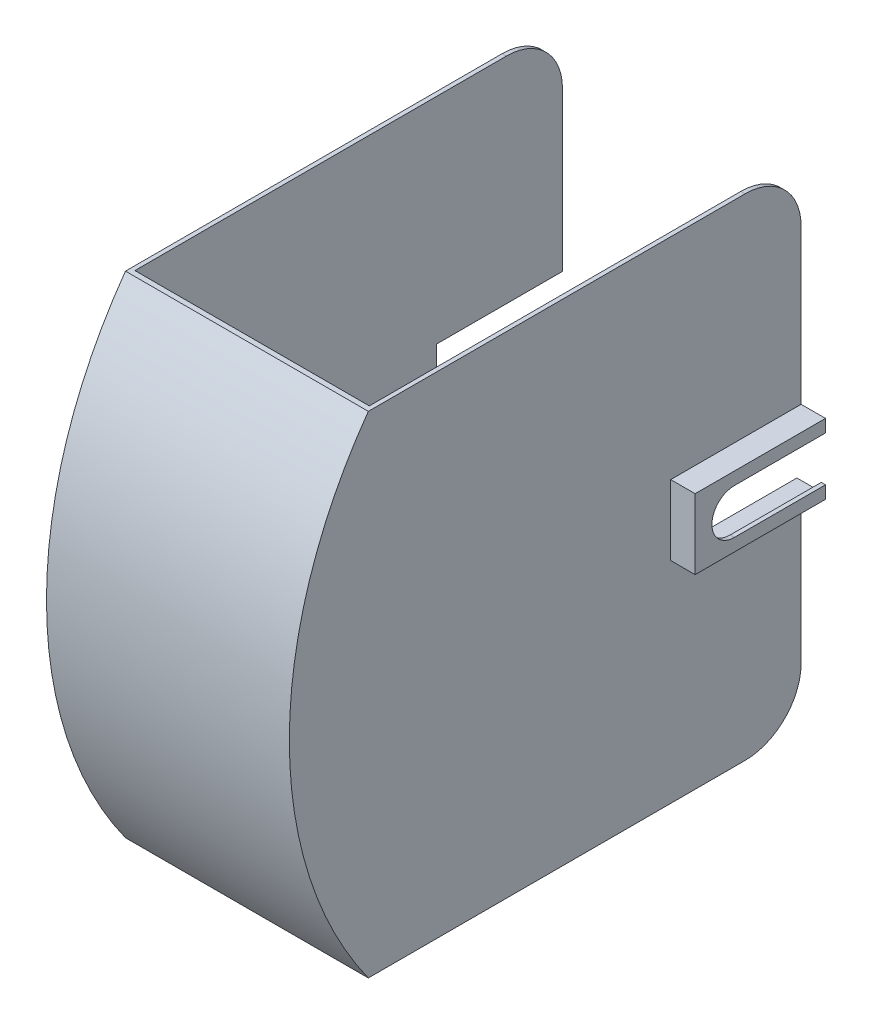
from build123d import *

# Parameters (mm, degrees)
BOSS_EXTRUDE1_DEPTH  = 90
CUT_EXTRUDE1_DEPTH   = 15
SKETCH4_W            = 3
SKETCH4_H            = 90
BOSS_EXTRUDE3_DEPTH  = 150
SKETCH5_W            = 3
SKETCH5_H            = 90
BOSS_EXTRUDE4_DEPTH  = 150
SKETCH12_W           = 20.399999779
SKETCH12_H           = 3
BOSS_EXTRUDE5_DEPTH  = 3
SKETCH13_W           = 20.399999779
SKETCH13_H           = 3
BOSS_EXTRUDE6_DEPTH  = 47
SKETCH15_W           = 3
SKETCH15_H           = 150
BOSS_EXTRUDE7_DEPTH  = 3
SKETCH16_W           = 3
SKETCH16_H           = 150
BOSS_EXTRUDE8_DEPTH  = 3
SKETCH17_W           = 3
SKETCH17_H           = 350
BOSS_EXTRUDE9_DEPTH  = 293
CUT_EXTRUDE2_DEPTH   = 263
BOSS_EXTRUDE10_DEPTH = 167.2
FILLET1_R            = 40


with BuildPart() as part:
    # Sketch2 → Boss-Extrude1 (new body)
    with BuildSketch(Plane.XY):
        Polygon((-54.932805324, 53.008197058), (-54.932805324, 97.008197058), (-72.332805103, 97.008197058), (-72.332805103, 100.008197058), (-51.932805324, 100.008197058), (-51.932805324, 50.008197058), (-72.332805103, 50.008197058), (-72.332805103, 53.008197058), align=None)
    extrude(amount=-BOSS_EXTRUDE1_DEPTH)

    # Sketch3 → Cut-Extrude1 (cut)
    with BuildSketch(Plane(origin=(-51.932805324, 0, 0), x_dir=(0, 0, -1), z_dir=(1, 0, 0))):
        with BuildLine():
            Line((25.000000095, 59.008197058), (90, 59.008197058))
            Line((90, 59.008197058), (90, 91.008197058))
            Line((90, 91.008197058), (25.000000095, 91.008197058))
            ThreePointArc((25.000000095, 91.008197058), (9.000000095, 75.008197058), (25.000000095, 59.008197058))
        make_face()
    extrude(amount=-CUT_EXTRUDE1_DEPTH, mode=Mode.SUBTRACT)

    # Sketch4 → Boss-Extrude3 (add)
    with BuildSketch(Plane.XZ.offset(-50.008197058)):
        with Locations((-70.832805103, -45)):
            Rectangle(SKETCH4_W, SKETCH4_H)
    extrude(amount=BOSS_EXTRUDE3_DEPTH)

    # Sketch5 → Boss-Extrude4 (add)
    with BuildSketch(Plane(origin=(0, 100.008197058, 0), x_dir=(1, 0, 0), z_dir=(0, 1, 0))):
        with Locations((-70.832805103, 45)):
            Rectangle(SKETCH5_W, SKETCH5_H)
    extrude(amount=BOSS_EXTRUDE4_DEPTH)

    # Sketch12 → Boss-Extrude5 (add)
    with BuildSketch(Plane.XY):
        with Locations((-62.132805213, 98.508197058)):
            Rectangle(SKETCH12_W, SKETCH12_H)
    extrude(amount=BOSS_EXTRUDE5_DEPTH)

    # Sketch13 → Boss-Extrude6 (add)
    with BuildSketch(Plane.XZ.offset(-97.008197058)):
        with Locations((-62.132805213, 1.5)):
            Rectangle(SKETCH13_W, SKETCH13_H)
    extrude(amount=BOSS_EXTRUDE6_DEPTH)

    # Sketch15 → Boss-Extrude7 (add)
    with BuildSketch(Plane.XY):
        with Locations((-70.832805103, -24.991802942)):
            Rectangle(SKETCH15_W, SKETCH15_H)
    extrude(amount=BOSS_EXTRUDE7_DEPTH)

    # Sketch16 → Boss-Extrude8 (add)
    with BuildSketch(Plane.XY):
        with Locations((-70.832805103, 175.008197058)):
            Rectangle(SKETCH16_W, SKETCH16_H)
    extrude(amount=BOSS_EXTRUDE8_DEPTH)

    # Sketch17 → Boss-Extrude9 (add)
    with BuildSketch(Plane.XY.offset(3)):
        with Locations((-70.832805103, 75.008197058)):
            Rectangle(SKETCH17_W, SKETCH17_H)
    extrude(amount=BOSS_EXTRUDE9_DEPTH)

    # Sketch18 → Cut-Extrude2 (cut)
    with BuildSketch(Plane(origin=(-69.332805103, 0, 0), x_dir=(0, 0, -1), z_dir=(1, 0, 0))):
        with BuildLine():
            Line((-218.669858525, -99.991802942), (-296, -99.991802942))
            Line((-296, -99.991802942), (-296, 250.008197058))
            Line((-296, 250.008197058), (-218.669858525, 250.008197058))
            ThreePointArc((-218.669858525, 250.008197058), (-274.999999905, 75.008197058), (-218.669858525, -99.991802942))
        make_face()
    extrude(amount=-CUT_EXTRUDE2_DEPTH, mode=Mode.SUBTRACT)


with BuildPart() as body_2:
    # Mirror3: mirrored copy
    add(part.part.mirror(Plane.ZY.offset(155.932805134)))


with BuildPart() as part_1:
    add(part.part)

    add(body_2.part)  # Boss-Extrude10 merges body 2
    # Sketch20 → Boss-Extrude10 (add)
    with BuildSketch(Plane.ZY.offset(72.332805103)):
        with BuildLine():
            Line((214.966664257, 250.008197058), (218.669858525, 250.008197058))
            ThreePointArc((218.669858525, 250.008197058), (274.999999905, 75.008197058), (218.669858525, -99.991802942))
            Line((218.669858525, -99.991802942), (214.966664257, -99.991802942))
            ThreePointArc((214.966664257, -99.991802942), (271.999999905, 75.008197058), (214.966664257, 250.008197058))
        make_face()
    extrude(amount=BOSS_EXTRUDE10_DEPTH)

    # Fillet1
    fillet1_edges = [part_1.edges().sort_by_distance(p)[0] for p in [
        (-241.032805165, 250.008197058, -90),
        (-241.032805165, -99.991802942, -90),
        (-70.832805103, -99.991802942, -90),
        (-70.832805103, 250.008197058, -90),
    ]]
    fillet(fillet1_edges, radius=FILLET1_R)


solid = part_1.part
